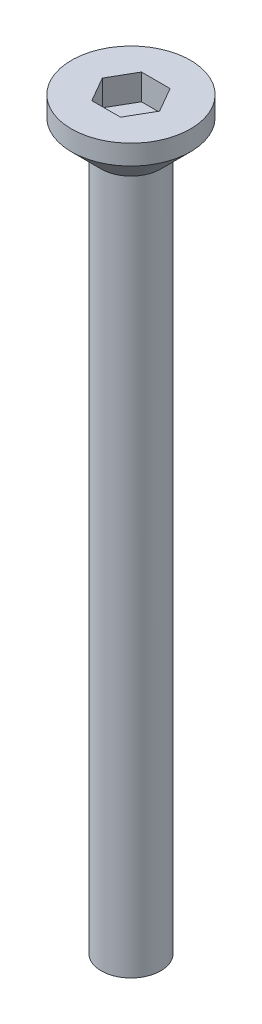
from build123d import *

# Parameters (mm, degrees)
SKETCH_1_R            = 3
EXTRUDE_251_DEPTH     = 2.5
CHAMFER_1_SIZE        = 1.5
CUT_EXTRUDE_459_DEPTH = 1.3
SKETCH_3_R            = 1.5
EXTRUDE_571_DEPTH     = 35


with BuildPart() as part:
    # 草图1 → Extrude 251 (new body)
    with BuildSketch(Plane(origin=(0, 0, 0), x_dir=(1, 0, 0), z_dir=(0, 1, 0))):
        Circle(SKETCH_1_R)
    extrude(amount=EXTRUDE_251_DEPTH)

    # 倒角1
    chamfer_1_edges = [part.edges().sort_by_distance(p)[0] for p in [
        (-3, 0, 0),
    ]]
    chamfer(chamfer_1_edges, length=CHAMFER_1_SIZE)

    # 草图2 → Cut-Extrude 459 (cut)
    with BuildSketch(Plane(origin=(0, 2.5, 0), x_dir=(1, 0, 0), z_dir=(0, 1, 0))):
        Polygon((1.443375673, 0), (0.721687836, 1.25), (-0.721687836, 1.25), (-1.443375673, 0), (-0.721687836, -1.25), (0.721687836, -1.25), align=None)
    extrude(amount=-CUT_EXTRUDE_459_DEPTH, mode=Mode.SUBTRACT)

    # 草图3 → Extrude 571 (add)
    with BuildSketch(Plane.XZ):
        Circle(SKETCH_3_R)
    extrude(amount=EXTRUDE_571_DEPTH)


solid = part.part
